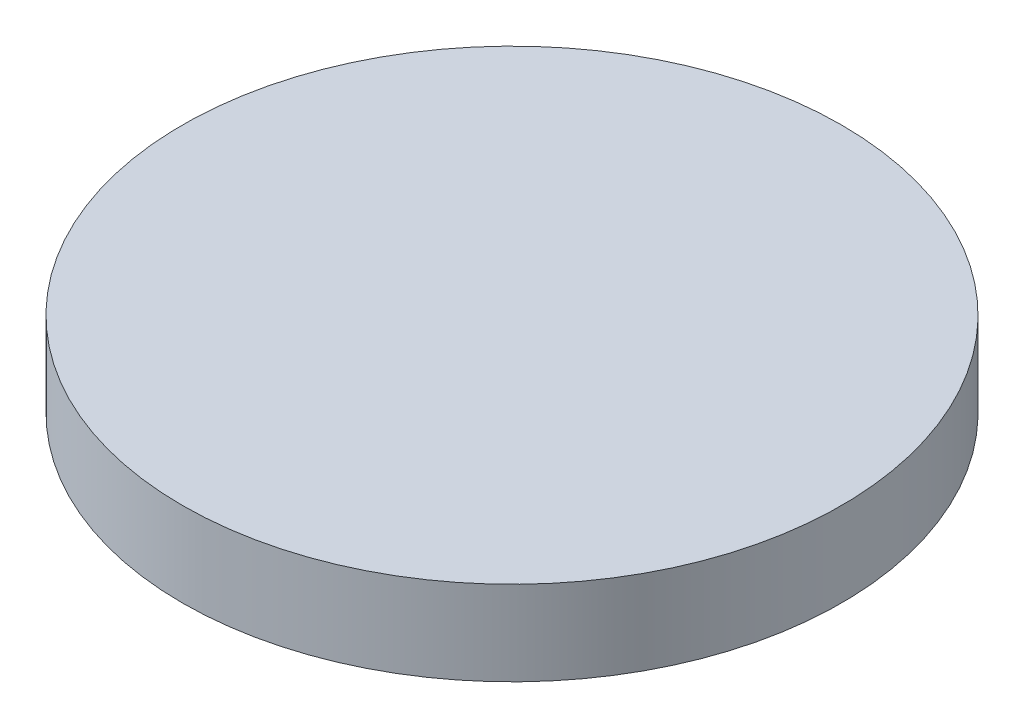
from build123d import *

# Parameters (mm, degrees)
SKETCH1_R           = 24.765
BOSS_EXTRUDE1_DEPTH = 6.35


with BuildPart() as part:
    # Sketch1 → Boss-Extrude1 (new body)
    with BuildSketch(Plane(origin=(0, 0, 0), x_dir=(1, 0, 0), z_dir=(0, 1, 0))):
        with Locations(Location((0, 0, 0), (0, 0, 270))):  # turned: the seam where the file's is
            Circle(SKETCH1_R)
    extrude(amount=BOSS_EXTRUDE1_DEPTH)


solid = part.part
